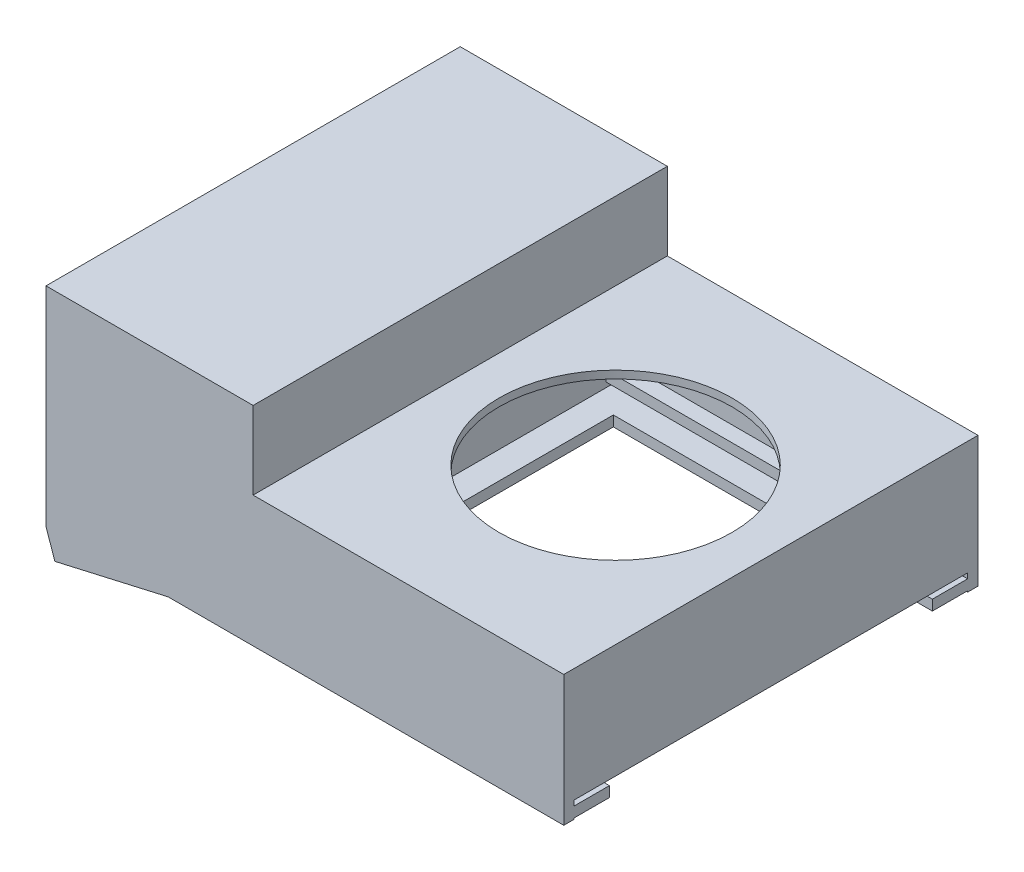
from build123d import *

# Parameters (mm, degrees)
BOSS_EXTRUDE1_DEPTH      = 80
BOSS_EXTRUDE2_DEPTH      = 25
SKETCH5_W                = 100
SKETCH5_H                = 2
BOSS_EXTRUDE3_DEPTH      = 1
BOSS_EXTRUDE3_DEPTH_BACK = 69
CUT_EXTRUDE1_DEPTH       = 54
CUT_EXTRUDE1_DEPTH_BACK  = 128
BOSS_EXTRUDE4_DEPTH      = 80
BOSS_EXTRUDE5_DEPTH      = 2
BOSS_EXTRUDE6_DEPTH      = 2
CUT_EXTRUDE2_DEPTH       = 10
SKETCH12_W               = 66.626507626
SKETCH12_H               = 2
BOSS_EXTRUDE7_DEPTH      = 3
SKETCH13_W               = 64.876762197
SKETCH13_H               = 2
BOSS_EXTRUDE8_DEPTH      = 3
CUT_EXTRUDE3_DEPTH       = 61.618605692


with BuildPart() as part:
    # Sketch1 → Boss-Extrude1 (new body)
    with BuildSketch(Plane.XY):
        Polygon((33.482657766, -45.251477229), (33.482657766, -66.768484939), (-31.394104431, -66.768484939), (-31.394104431, -53.768484939), (-54.654934222, -68.768484939), (35.482657766, -68.768484939), (35.482657766, -43.768484939), (-24.517342234, -43.768484939), (-24.517342234, -28.768484939), (-64.517342234, -28.768484939), (-64.517342234, -68.768484939), (-62.012951809, -68.768484939), (-62.012951809, -63.171810384), (-27.383124188, -45.251477229), align=None)
    extrude(amount=BOSS_EXTRUDE1_DEPTH)

    # Sketch4 → Boss-Extrude2 (add)
    with BuildSketch(Plane(origin=(0, -43.768484939, 0), x_dir=(1, 0, 0), z_dir=(0, 1, 0))):
        Polygon((-54.654934222, -80), (-31.394104431, -80), (-31.394104431, -55), align=None)
        Polygon((-54.654934222, 0), (-31.394104431, 0), (-31.394104431, -25), align=None)
    extrude(amount=-BOSS_EXTRUDE2_DEPTH)

    # Sketch5 → Boss-Extrude3 (add, two sides)
    with BuildSketch(Plane(origin=(0, 0, 0), x_dir=(1, 0, 0), z_dir=(0, 1, 0))) as boss_extrude3_sk:
        with Locations((-14.517342234, -79)):
            Rectangle(SKETCH5_W, SKETCH5_H)
        with Locations((-14.517342234, -1)):
            Rectangle(SKETCH5_W, SKETCH5_H)
    extrude(amount=BOSS_EXTRUDE3_DEPTH)
    extrude(boss_extrude3_sk.sketch, amount=-BOSS_EXTRUDE3_DEPTH_BACK)

    # Sketch6 → Cut-Extrude1 (cut, two sides)
    with BuildSketch(Plane(origin=(0, 0, 0), x_dir=(-1, 0, 0), z_dir=(0, 0, -1))) as cut_extrude1_sk:
        Polygon((64.517342234, -28.768484939), (24.517342234, -28.768484939), (24.517342234, -43.768484939), (-35.482657766, -43.768484939), (-64.959998335, 15.691238157), (80.820060582, 20.703322698), align=None)
    extrude(amount=CUT_EXTRUDE1_DEPTH, mode=Mode.SUBTRACT)
    extrude(cut_extrude1_sk.sketch, amount=-CUT_EXTRUDE1_DEPTH_BACK, mode=Mode.SUBTRACT)

    # Sketch7 → Boss-Extrude4 (add)
    with BuildSketch(Plane.XY.offset(80)):
        Polygon((-40.942007341, -69), (-55.024396115, -69), (-62.814493255, -74), align=None)
        Polygon((-47.280486214, -68.008659762), (-52.794067838, -67.568484939), (-55.024396115, -69), (-40.942007341, -69), (-39.368534116, -68.640307638), align=None)
    extrude(amount=-BOSS_EXTRUDE4_DEPTH)

    # Sketch9 → Boss-Extrude5 (add)
    with BuildSketch(Plane.XY.offset(80)):
        Polygon((-64.517342234, -69), (-55.024396115, -69), (-62.814493255, -74), align=None)
    extrude(amount=-BOSS_EXTRUDE5_DEPTH)

    # Sketch10 → Boss-Extrude6 (add)
    with BuildSketch(Plane(origin=(0, 0, 0), x_dir=(-1, 0, 0), z_dir=(0, 0, -1))):
        Polygon((64.517342234, -69), (55.024396115, -69), (62.814493255, -74), align=None)
    extrude(amount=-BOSS_EXTRUDE6_DEPTH)

    # Sketch11 → Cut-Extrude2 (cut)
    with BuildSketch(Plane(origin=(0, -43.768484939, 0), x_dir=(1, 0, 0), z_dir=(0, 1, 0))):
        with BuildLine():
            ThreePointArc((-17.017342234, -40), (5.482657766, -62.5), (27.982657766, -40))
            Line((27.982657766, -40), (-17.017342234, -40))
        make_face()
        with BuildLine():
            Line((-17.017342234, -40), (27.982657766, -40))
            ThreePointArc((27.982657766, -40), (5.482657766, -17.5), (-17.017342234, -40))
        make_face()
    extrude(amount=-CUT_EXTRUDE2_DEPTH, mode=Mode.SUBTRACT)

    # Sketch12 → Boss-Extrude7 (add)
    with BuildSketch(Plane(origin=(0, 0, 78), x_dir=(-1, 0, 0), z_dir=(0, 0, -1))):
        with Locations((-1.919149382, -64.768484939)):
            Rectangle(SKETCH12_W, SKETCH12_H)
    extrude(amount=BOSS_EXTRUDE7_DEPTH)

    # Sketch13 → Boss-Extrude8 (add)
    with BuildSketch(Plane.XY.offset(2)):
        with Locations((1.044276668, -64.768484939)):
            Rectangle(SKETCH13_W, SKETCH13_H)
    extrude(amount=BOSS_EXTRUDE8_DEPTH)

    # Sketch14 → Cut-Extrude3 (cut)
    with BuildSketch(Plane(origin=(35.482657766, 0, 0), x_dir=(0, 0, -1), z_dir=(1, 0, 0))):
        Polygon((-2, -65.768484939), (-78, -65.768484939), (-78, -66.768484939), (-71.1896289, -66.768484939), (-71.1896289, -68.768484939), (-40, -68.768484939), (-8.8103711, -68.768484939), (-8.8103711, -66.768484939), (-2, -66.768484939), align=None)
    extrude(amount=-CUT_EXTRUDE3_DEPTH, mode=Mode.SUBTRACT)


solid = part.part
